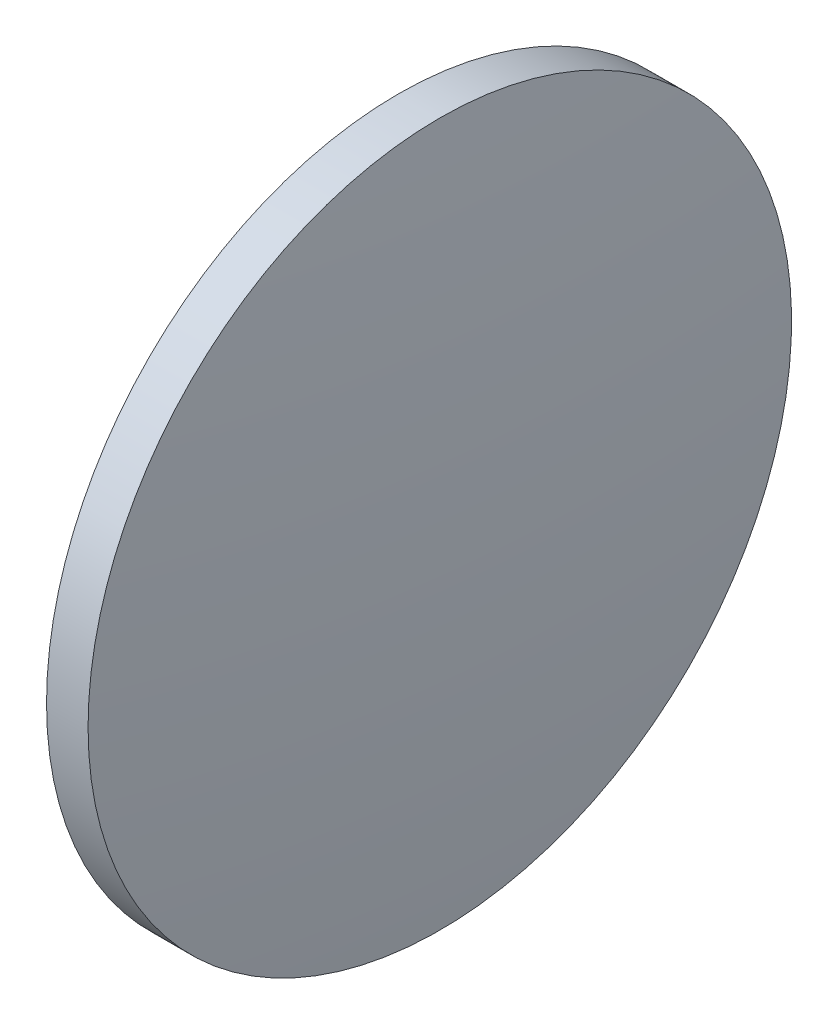
from build123d import *

# Parameters (mm, degrees)
SKETCH_1_ONE_SIDE_W = 2.999957714
SKETCH_1_ONE_SIDE_H = 25.4


with BuildPart() as part:
    # 草图1 one side → 旋转1 (revolve)
    with BuildSketch(Plane.XY):
        with Locations((172.916387549, 109.932226046)):
            Rectangle(SKETCH_1_ONE_SIDE_W, SKETCH_1_ONE_SIDE_H)
        with BuildLine():
            Line((170.216440121, 97.232226046), (171.416408692, 97.232226046))
            Line((171.416408692, 97.232226046), (171.416408692, 122.632226046))
            ThreePointArc((171.416408692, 122.632226046), (170.516599464, 109.946390633), (170.216440121, 97.232226046))
        make_face()
        with BuildLine():
            Line((174.416366406, 97.232226046), (175.616334978, 97.232226046))
            ThreePointArc((175.616334978, 97.232226046), (175.316175634, 109.946390633), (174.416366406, 122.632226046))
            Line((174.416366406, 122.632226046), (174.416366406, 97.232226046))
        make_face()
    revolve(axis=Axis((165.744107942, 97.232226046, 0), (1, 0, 0)))


solid = part.part
